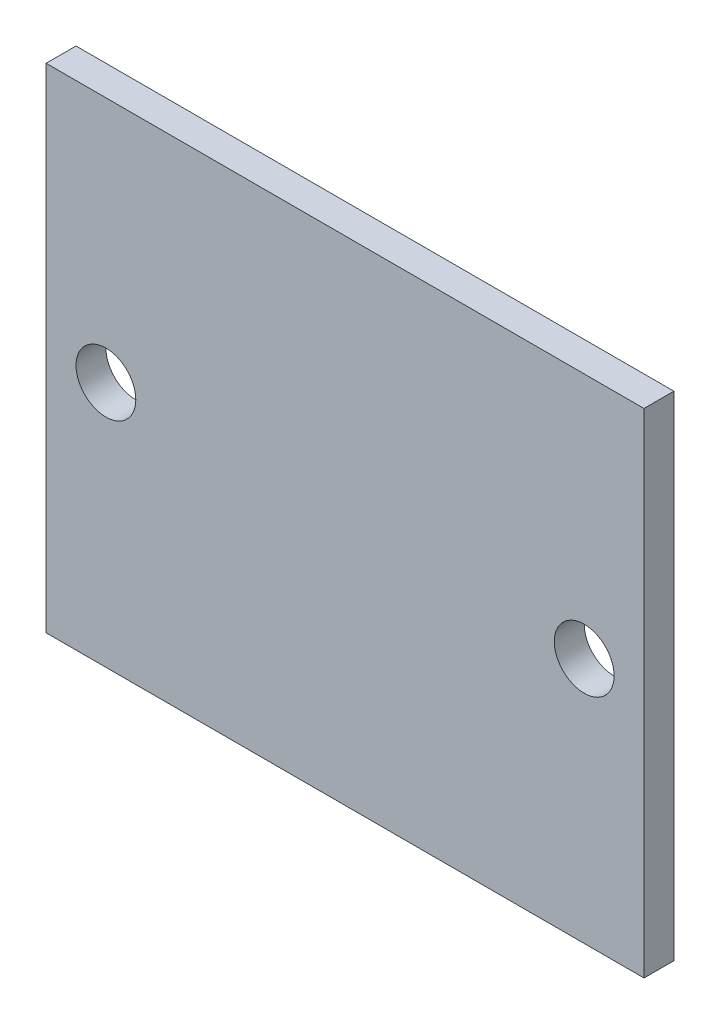
from build123d import *

# Parameters (mm, degrees)
SKIZZE1_W                       = 20
SKIZZE1_H                       = 16.5
AUFSATZ_LINEAR_AUSTRAGEN1_DEPTH = 1
SKIZZE2_R                       = 1
SCHNITT_LINEAR_AUSTRAGEN1_DEPTH = 2


with BuildPart() as part:
    # Skizze1 → Aufsatz-Linear austragen1 (new body)
    with BuildSketch(Plane.XY):
        Rectangle(SKIZZE1_W, SKIZZE1_H)
    extrude(amount=AUFSATZ_LINEAR_AUSTRAGEN1_DEPTH)

    # Skizze2 → Schnitt-Linear austragen1 (cut, through all)
    with BuildSketch(Plane.XY.offset(1)):
        with Locations((-8, 0)):
            Circle(SKIZZE2_R)
        with Locations((8, 0)):
            Circle(SKIZZE2_R)
    extrude(amount=-SCHNITT_LINEAR_AUSTRAGEN1_DEPTH, mode=Mode.SUBTRACT)


solid = part.part
